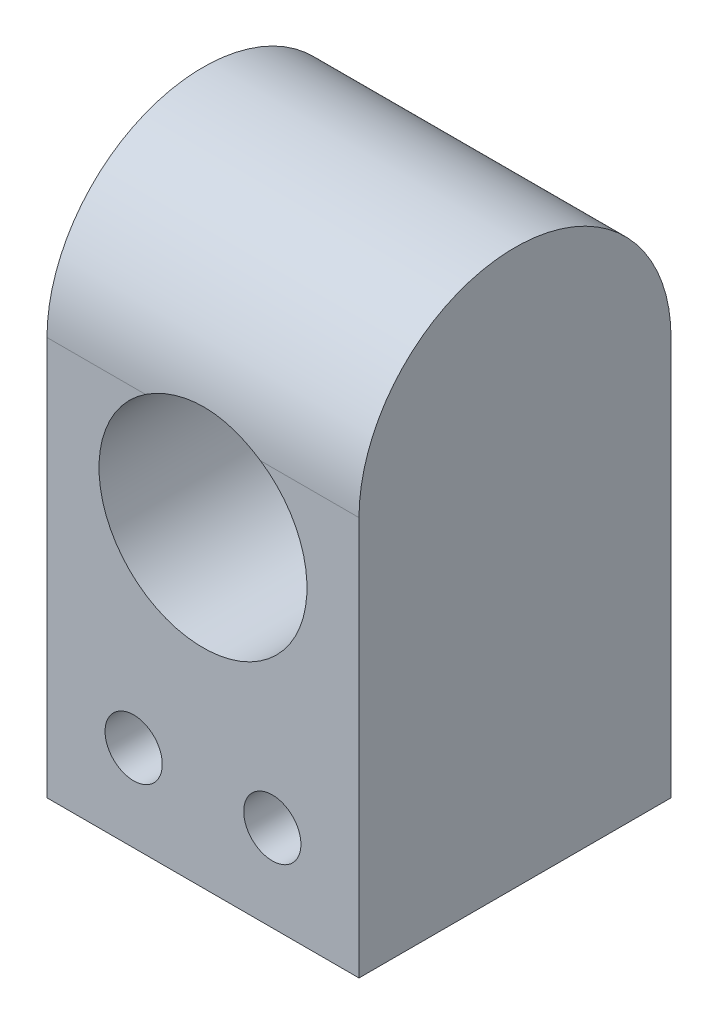
from build123d import *

# Parameters (mm, degrees)
BOSS_EXTRUDE1_DEPTH   = 18
SKETCH2_R             = 6
CUT_EXTRUDE1_DEPTH    = 18
M4X0_7_TAPPED_HOLE1_D = 3.3


with BuildPart() as part:
    # Sketch1 → Boss-Extrude1 (new body)
    with BuildSketch(Plane(origin=(0, 0, 0), x_dir=(0, 0, -1), z_dir=(1, 0, 0))):
        with BuildLine():
            Line((-9, -11.5), (9, -11.5))
            Line((9, -11.5), (9, 11.5))
            ThreePointArc((9, 11.5), (0, 20.5), (-9, 11.5))
            Line((-9, 11.5), (-9, -11.5))
        make_face()
    extrude(amount=BOSS_EXTRUDE1_DEPTH)

    # Sketch2 → Cut-Extrude1 (cut)
    with BuildSketch(Plane.XY.offset(9)):
        with Locations(Location((9, 6.5, 0), (0, 0, 56.442690238))):  # turned: the seam where the file's is
            Circle(SKETCH2_R)
    extrude(amount=-CUT_EXTRUDE1_DEPTH, mode=Mode.SUBTRACT)

    # M4x0.7 Tapped Hole1 (through all)
    with Locations(Plane.XY.offset(9)):
        with Locations((5, -6.5), (13, -6.5)):
            Hole(M4X0_7_TAPPED_HOLE1_D / 2)


solid = part.part
